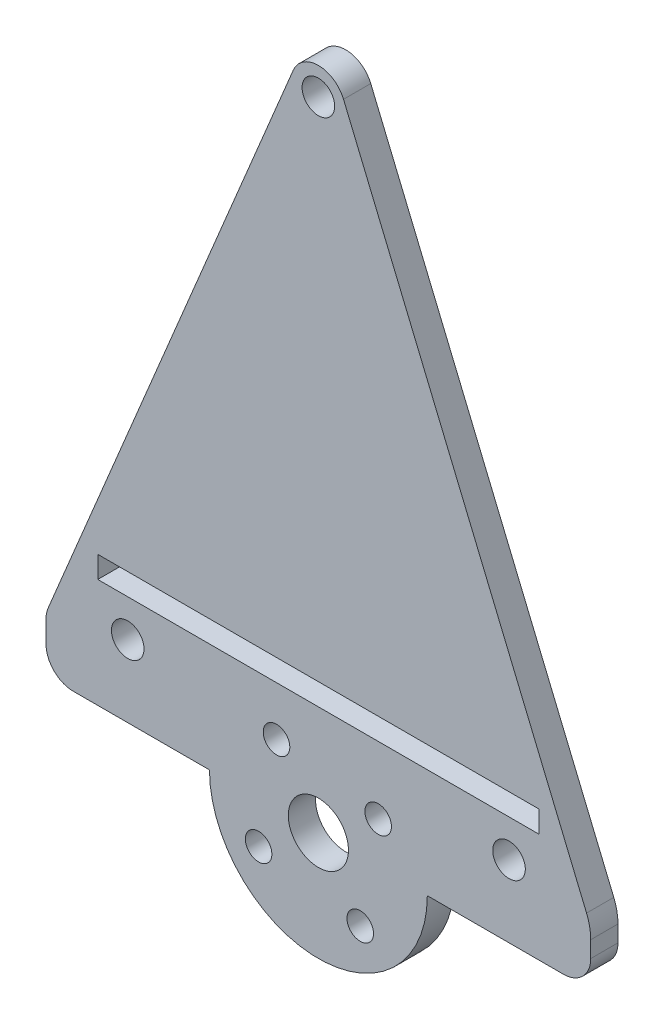
from build123d import *

# Parameters (mm, degrees)
BOSS_EXTRUDE1_DEPTH = 3.175
FILLET4_R           = 3.175
FILLET5_R           = 3.175
FILLET6_R           = 3.175
FILLET7_R           = 6.35
FILLET8_R           = 3.175
SKETCH2_R           = 3.5052
SKETCH2_R_2         = 1.5494
CUT_EXTRUDE1_DEPTH  = 4.175
SKETCH4_W           = 51.435
SKETCH4_H           = 2.54
CUT_EXTRUDE2_DEPTH  = 4.175
SKETCH10_R          = 1.89865
CUT_EXTRUDE3_DEPTH  = 4.175
SKETCH11_R          = 1.89865
CUT_EXTRUDE4_DEPTH  = 4.175


with BuildPart() as part:
    # Sketch1 → Boss-Extrude1 (new body)
    with BuildSketch(Plane.XY):
        with BuildLine():
            Line((-31.75, 0), (-31.75, -6.35))
            Line((-31.75, -6.35), (-12.7, -6.35))
            ThreePointArc((-12.7, -6.35), (0, -19.05), (12.7, -6.35))
            Line((12.7, -6.35), (31.75, -6.35))
            Line((31.75, -6.35), (31.75, 0))
            Line((31.75, 0), (0, 76.2))
            Line((0, 76.2), (-31.75, 0))
        make_face()
    extrude(amount=BOSS_EXTRUDE1_DEPTH)

    # Fillet4
    fillet4_edges = [part.edges().sort_by_distance(p)[0] for p in [
        (-31.75, -6.35, 1.5875),
    ]]
    fillet(fillet4_edges, radius=FILLET4_R)

    # Fillet5
    fillet5_edges = [part.edges().sort_by_distance(p)[0] for p in [
        (-31.75, 0, 1.5875),
    ]]
    fillet(fillet5_edges, radius=FILLET5_R)

    # Fillet6
    fillet6_edges = [part.edges().sort_by_distance(p)[0] for p in [
        (0, 76.2, 1.5875),
    ]]
    fillet(fillet6_edges, radius=FILLET6_R)

    # Fillet7
    fillet7_edges = [part.edges().sort_by_distance(p)[0] for p in [
        (31.75, 0, 1.5875),
    ]]
    fillet(fillet7_edges, radius=FILLET7_R)

    # Fillet8
    fillet8_edges = [part.edges().sort_by_distance(p)[0] for p in [
        (31.75, -6.35, 1.5875),
    ]]
    fillet(fillet8_edges, radius=FILLET8_R)

    # Sketch2 → Cut-Extrude1 (cut, through all)
    with BuildSketch(Plane.XY.offset(3.175)):
        with Locations((0, -6.35)):
            Circle(SKETCH2_R)
        with Locations((-4.880561897, 0.620164745)):
            Circle(SKETCH2_R_2)
        with Locations((4.880561897, -13.320164745)):
            Circle(SKETCH2_R_2)
        with Locations((6.970164745, -1.469438103)):
            Circle(SKETCH2_R_2)
        with Locations((-6.970164745, -11.230561897)):
            Circle(SKETCH2_R_2)
    extrude(amount=-CUT_EXTRUDE1_DEPTH, mode=Mode.SUBTRACT)

    # Sketch4 → Cut-Extrude2 (cut, through all)
    with BuildSketch(Plane.XY.offset(3.175)):
        with Locations((0, 7.634999946)):
            Rectangle(SKETCH4_W, SKETCH4_H)
    extrude(amount=-CUT_EXTRUDE2_DEPTH, mode=Mode.SUBTRACT)

    # Sketch10 → Cut-Extrude3 (cut, through all)
    with BuildSketch(Plane.XY.offset(3.175)):
        with Locations((-22.225, 2.034299946)):
            Circle(SKETCH10_R)
        with Locations((22.225, 2.034299946)):
            Circle(SKETCH10_R)
    extrude(amount=-CUT_EXTRUDE3_DEPTH, mode=Mode.SUBTRACT)

    # Sketch11 → Cut-Extrude4 (cut, through all)
    with BuildSketch(Plane.XY.offset(3.175)):
        with Locations((0, 67.945)):
            Circle(SKETCH11_R)
    extrude(amount=-CUT_EXTRUDE4_DEPTH, mode=Mode.SUBTRACT)


solid = part.part
